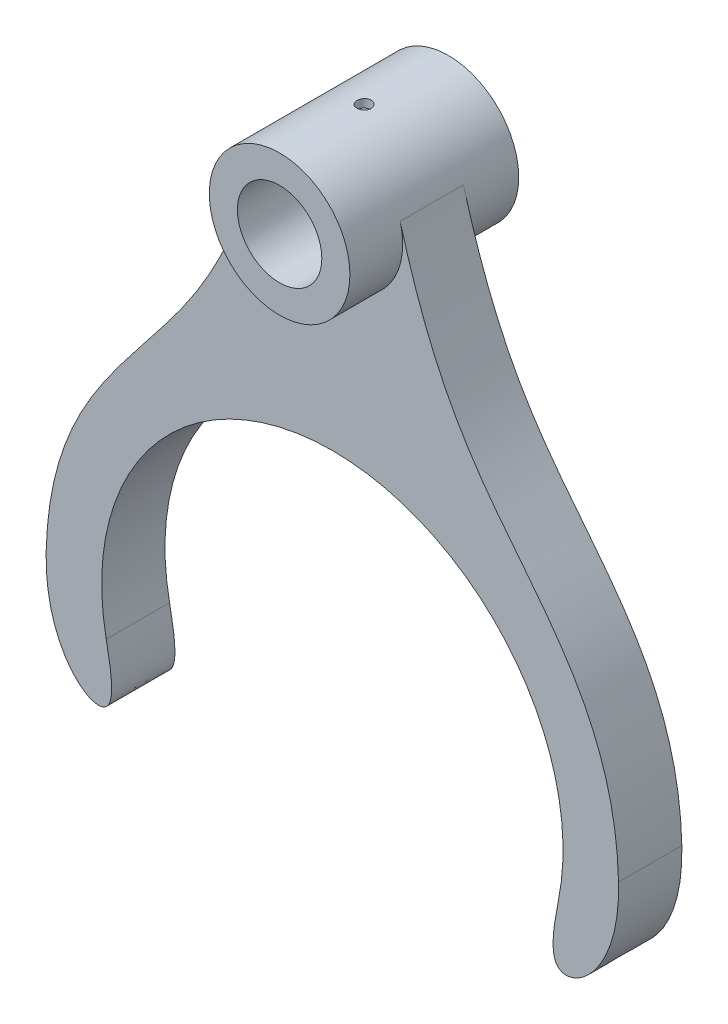
from build123d import *

# Parameters (mm, degrees)
BOSS_EXTRUDE1_DEPTH = 11.25
SKETCH1_3_R         = 25
SKETCH1_3_R_2       = 15
BOSS_EXTRUDE2_DEPTH = 30
SKETCH3_R           = 2.5
CUT_EXTRUDE1_DEPTH  = 243.435035461


with BuildPart() as part:
    # Sketch1 → Boss-Extrude1 (new, symmetric)
    with BuildSketch(Plane.XY):
        with BuildLine():
            ThreePointArc((-80.369346148, -16.271699348), (0, 82), (80.369346148, -16.271699348))
            add(Edge.make_bspline(
                [(80.369346148, -16.271699348), (78.198626966, -26.993338043), (76.506237686, -48.322432058), (102.498129601, -29.89988011), (100.620263928, 43.938366918), (64.346417004, 80.312533322), (34.633446861, 126.224897928), (24.110391918, 164.609765621)],
                knots=[0, 0, 0, 0, 0.323439869, 1, 1, 1.99421627, 2.660997613, 2.660997613, 2.660997613, 2.660997613], degree=3))
            ThreePointArc((24.110391918, 164.609765621), (0, 133), (-24.110391918, 164.609765621))
            add(Edge.make_bspline(
                [(-24.110391918, 164.609765621), (-34.633446861, 126.224897928), (-64.346417004, 80.312533322), (-100.620263928, 43.938366918), (-102.498129601, -29.89988011), (-76.506237686, -48.322432058), (-78.198626966, -26.993338043), (-80.369346148, -16.271699348)],
                knots=[0, 0, 0, 0, 0.401434257, 1, 1, 1.407321555, 1.602047825, 1.602047825, 1.602047825, 1.602047825], degree=3))
        make_face()
    extrude(amount=BOSS_EXTRUDE1_DEPTH, both=True)

    # Sketch1_3 → Boss-Extrude2 (add, symmetric)
    with BuildSketch(Plane.XY):
        with Locations((0, 158)):
            Circle(SKETCH1_3_R)
        with Locations((0, 158)):
            Circle(SKETCH1_3_R_2, mode=Mode.SUBTRACT)
    extrude(amount=BOSS_EXTRUDE2_DEPTH, both=True)

    # Sketch3 → Cut-Extrude1 (cut, through all)
    with BuildSketch(Plane(origin=(0, 180, 0), x_dir=(1, 0, 0), z_dir=(0, 1, 0))):
        Circle(SKETCH3_R)
    extrude(amount=CUT_EXTRUDE1_DEPTH, mode=Mode.SUBTRACT)


solid = part.part
